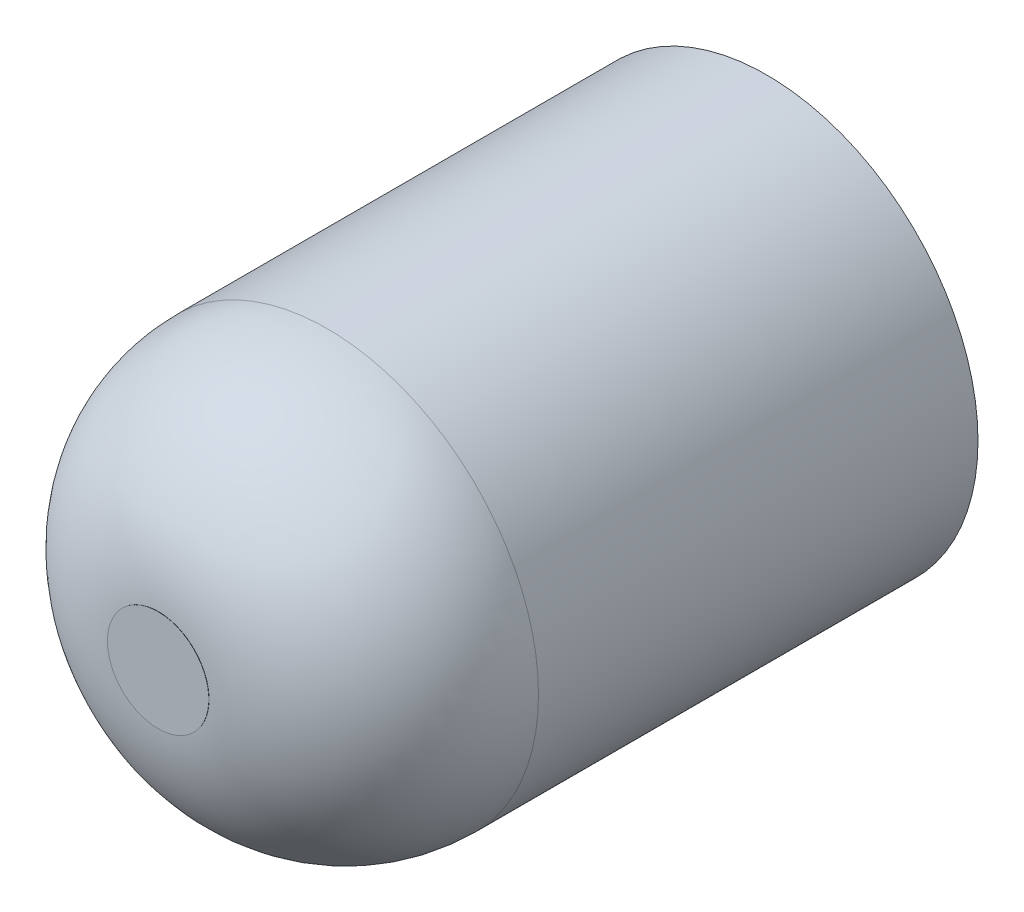
from build123d import *

# Parameters (mm, degrees)
CROQUIS1_R                   = 9.5
CROQUIS1_R_2                 = 3
SALIENTE_EXTRUIR1_DEPTH      = 6
CROQUIS3_R                   = 12.5
SALIENTE_EXTRUIR3_DEPTH      = 16
REDONDEO1_R                  = 10
CROQUIS5_R                   = 3
CORTAR_EXTRUIR1_DEPTH        = 20
CROQUIS6_R                   = 3
SALIENTE_EXTRUIR4_DEPTH      = 22
SALIENTE_EXTRUIR4_DEPTH_BACK = 16
CROQUIS9_R                   = 12.5
SALIENTE_EXTRUIR5_DEPTH      = 20


with BuildPart() as part:
    # Croquis1 → Saliente-Extruir1 (new body)
    with BuildSketch(Plane.XY):
        Circle(CROQUIS1_R)
        Circle(CROQUIS1_R_2, mode=Mode.SUBTRACT)
    extrude(amount=SALIENTE_EXTRUIR1_DEPTH)



with BuildPart() as body_2:
    # Croquis3 → Saliente-Extruir3 (new body)
    with BuildSketch(Plane(origin=(0, 0, 0), x_dir=(-1, 0, 0), z_dir=(0, 0, -1))):
        Circle(CROQUIS3_R)
    extrude(amount=SALIENTE_EXTRUIR3_DEPTH)

    # Redondeo1
    redondeo1_edges = [body_2.edges().sort_by_distance(p)[0] for p in [
        (12.5, 0, -16),
    ]]
    fillet(redondeo1_edges, radius=REDONDEO1_R)

    # Croquis5 → Cortar-Extruir1 (cut)
    with BuildSketch(Plane.XY):
        Circle(CROQUIS5_R)
    extrude(amount=-CORTAR_EXTRUIR1_DEPTH, mode=Mode.SUBTRACT)


with BuildPart() as body_3:
    # Simetría1: mirrored copy
    add(body_2.part.mirror(Plane(origin=(0, 0, 3), x_dir=(1, 0, 0), z_dir=(0, 0, -1))))


with BuildPart() as body_4:
    # Croquis6 → Saliente-Extruir4 (new body, two sides)
    with BuildSketch(Plane(origin=(0, 0, 6), x_dir=(-1, 0, 0), z_dir=(0, 0, -1))) as saliente_extruir4_sk:
        Circle(CROQUIS6_R)
    extrude(amount=SALIENTE_EXTRUIR4_DEPTH)
    extrude(saliente_extruir4_sk.sketch, amount=-SALIENTE_EXTRUIR4_DEPTH_BACK)


with BuildPart() as part_1:
    add(part.part)

    add(body_3.part)  # Saliente-Extruir5 merges body 3

    add(body_4.part)  # Saliente-Extruir5 merges body 4
    # Croquis9 → Saliente-Extruir5 (add)
    with BuildSketch(Plane(origin=(0, 0, 6), x_dir=(-1, 0, 0), z_dir=(0, 0, -1))):
        Circle(CROQUIS9_R)
    extrude(amount=SALIENTE_EXTRUIR5_DEPTH)


solid = Compound([body_2.part, part_1.part])
